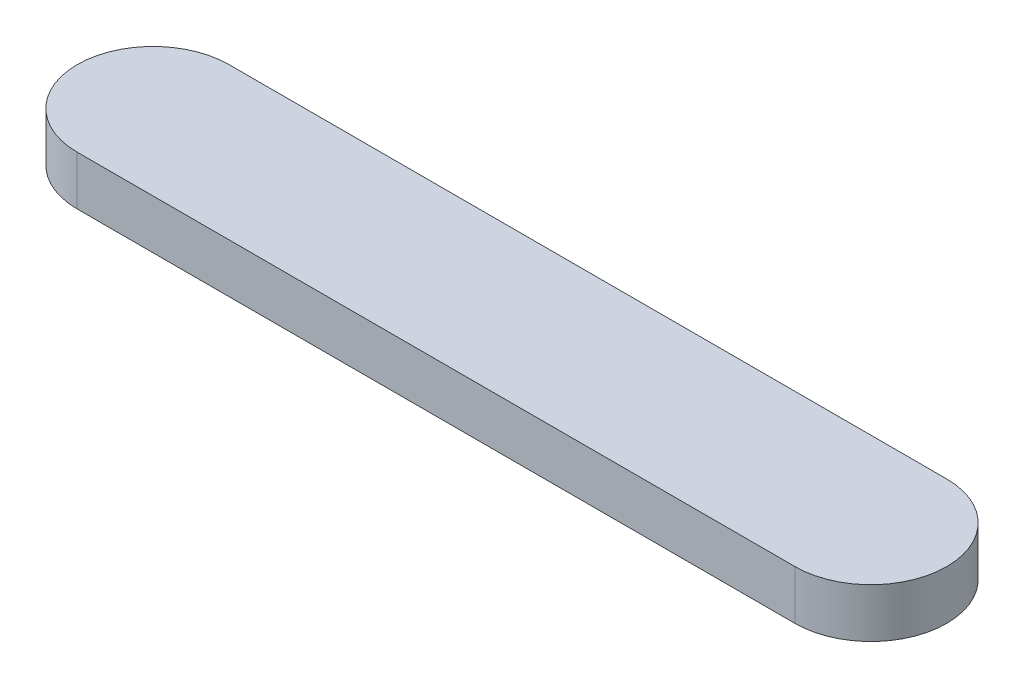
from build123d import *

# Parameters (mm, degrees)
BOSS_EXTRUDE1_DEPTH = 4.8


with BuildPart() as part:
    # Sketch1 → Boss-Extrude1 (new body)
    with BuildSketch(Plane(origin=(0, 0, 0), x_dir=(1, 0, 0), z_dir=(0, 1, 0))):
        with BuildLine():
            Line((0, 7.4), (70, 7.4))
            ThreePointArc((70, 7.4), (77.4, 0), (70, -7.4))
            Line((70, -7.4), (0, -7.4))
            ThreePointArc((0, -7.4), (-7.4, 0), (0, 7.4))
        make_face()
    extrude(amount=BOSS_EXTRUDE1_DEPTH)


solid = part.part
